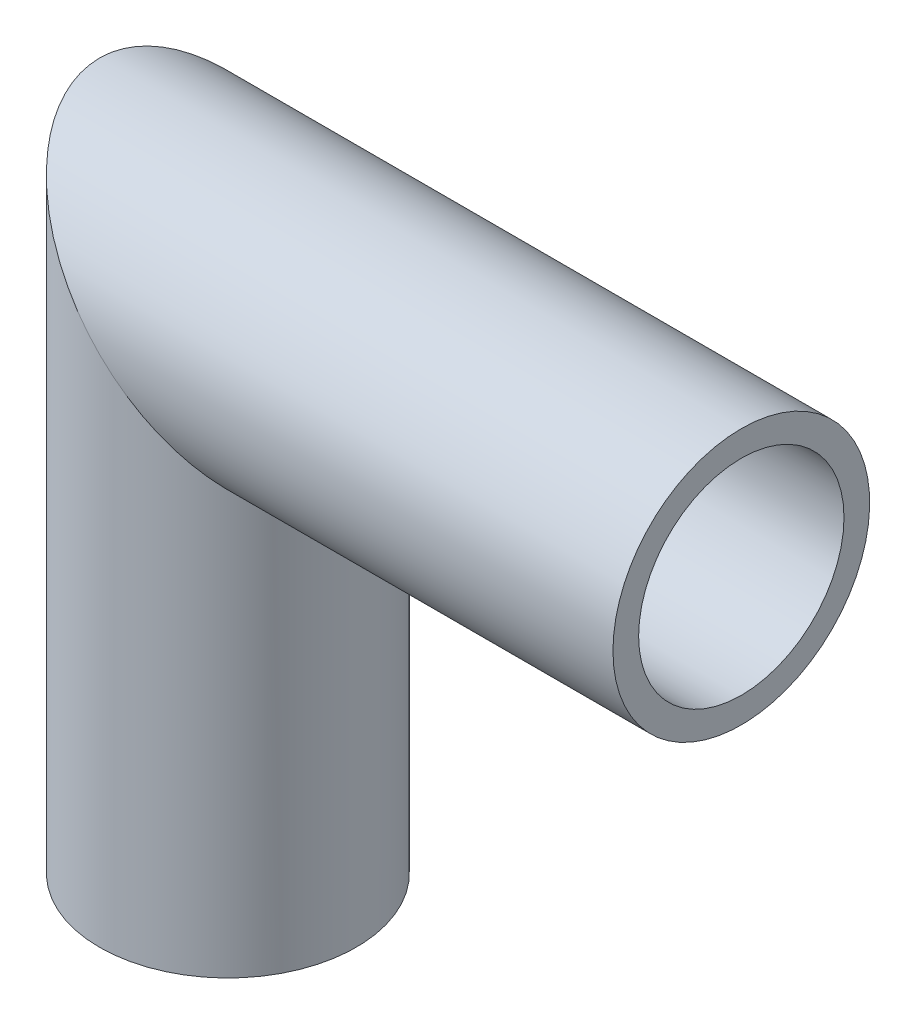
from build123d import *

# Parameters (mm, degrees)
SKETCH_1_R   = 12.5
SKETCH_1_R_2 = 10


with BuildPart() as part:
    # 扫描1: sweep along a path in 草图2
    with BuildLine(Plane.XY) as sweep_1_path:
        Line((0, 0), (0, 50))
        Line((0, 50), (50, 50))
    # 草图1 → 扫描1 (sweep)
    with BuildSketch(Plane(origin=(0, 0, 0), x_dir=(1, 0, 0), z_dir=(0, 1, 0))):
        Circle(SKETCH_1_R)
        Circle(SKETCH_1_R_2, mode=Mode.SUBTRACT)
    sweep(path=sweep_1_path.line, transition=Transition.RIGHT)


solid = part.part
